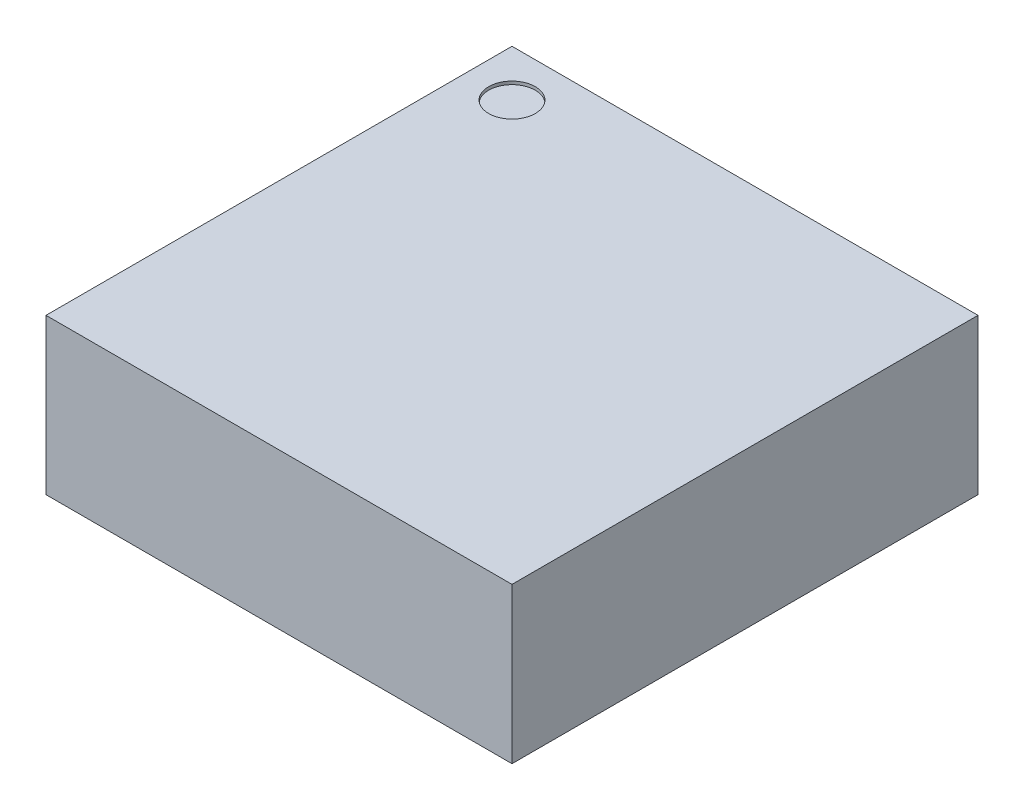
from build123d import *

# Parameters (mm, degrees)
SKETCH1_W           = 3
SKETCH1_H           = 3
BOSS_EXTRUDE1_DEPTH = 1
BOSS_EXTRUDE2_DEPTH = 0.05
SKETCH3_R           = 0.15
CUT_EXTRUDE1_DEPTH  = 0.02


with BuildPart() as part:
    # Sketch1 → Boss-Extrude1 (new body)
    with BuildSketch(Plane(origin=(0, 0, 0), x_dir=(1, 0, 0), z_dir=(0, 1, 0))):
        Rectangle(SKETCH1_W, SKETCH1_H)
    extrude(amount=BOSS_EXTRUDE1_DEPTH)

    # Sketch2 → Boss-Extrude2 (add)
    with BuildSketch(Plane.XZ):
        with BuildLine():
            Line((-0.6, 1.39), (-0.4, 1.39))
            ThreePointArc((-0.4, 1.39), (-0.364644661, 1.375355339), (-0.35, 1.34))
            Line((-0.35, 1.34), (-0.35, 0.98))
            ThreePointArc((-0.35, 0.98), (-0.5, 0.83), (-0.65, 0.98))
            Line((-0.65, 0.98), (-0.65, 1.34))
            ThreePointArc((-0.65, 1.34), (-0.635355339, 1.375355339), (-0.6, 1.39))
        make_face()
        with BuildLine():
            Line((-0.1, 1.39), (0.1, 1.39))
            ThreePointArc((0.1, 1.39), (0.135355339, 1.375355339), (0.15, 1.34))
            Line((0.15, 1.34), (0.15, 0.98))
            ThreePointArc((0.15, 0.98), (0, 0.83), (-0.15, 0.98))
            Line((-0.15, 0.98), (-0.15, 1.34))
            ThreePointArc((-0.15, 1.34), (-0.135355339, 1.375355339), (-0.1, 1.39))
        make_face()
        with BuildLine():
            Line((0.4, 1.39), (0.6, 1.39))
            ThreePointArc((0.6, 1.39), (0.635355339, 1.375355339), (0.65, 1.34))
            Line((0.65, 1.34), (0.65, 0.98))
            ThreePointArc((0.65, 0.98), (0.5, 0.83), (0.35, 0.98))
            Line((0.35, 0.98), (0.35, 1.34))
            ThreePointArc((0.35, 1.34), (0.364644661, 1.375355339), (0.4, 1.39))
        make_face()
        with BuildLine():
            Line((0.35, -0.98), (0.35, -1.34))
            ThreePointArc((0.35, -1.34), (0.364644661, -1.375355339), (0.4, -1.39))
            Line((0.4, -1.39), (0.6, -1.39))
            ThreePointArc((0.6, -1.39), (0.635355339, -1.375355339), (0.65, -1.34))
            Line((0.65, -1.34), (0.65, -0.98))
            ThreePointArc((0.65, -0.98), (0.5, -0.83), (0.35, -0.98))
        make_face()
        with BuildLine():
            Line((-0.15, -0.98), (-0.15, -1.34))
            ThreePointArc((-0.15, -1.34), (-0.135355339, -1.375355339), (-0.1, -1.39))
            Line((-0.1, -1.39), (0.1, -1.39))
            ThreePointArc((0.1, -1.39), (0.135355339, -1.375355339), (0.15, -1.34))
            Line((0.15, -1.34), (0.15, -0.98))
            ThreePointArc((0.15, -0.98), (0, -0.83), (-0.15, -0.98))
        make_face()
        with BuildLine():
            Line((-0.65, -0.98), (-0.65, -1.34))
            ThreePointArc((-0.65, -1.34), (-0.635355339, -1.375355339), (-0.6, -1.39))
            Line((-0.6, -1.39), (-0.4, -1.39))
            ThreePointArc((-0.4, -1.39), (-0.364644661, -1.375355339), (-0.35, -1.34))
            Line((-0.35, -1.34), (-0.35, -0.98))
            ThreePointArc((-0.35, -0.98), (-0.5, -0.83), (-0.65, -0.98))
        make_face()
        with BuildLine():
            Line((-1.34, 1.15), (-0.98, 1.15))
            ThreePointArc((-0.98, 1.15), (-0.83, 1), (-0.98, 0.85))
            Line((-0.98, 0.85), (-1.34, 0.85))
            ThreePointArc((-1.34, 0.85), (-1.375355339, 0.864644661), (-1.39, 0.9))
            Line((-1.39, 0.9), (-1.39, 1.1))
            ThreePointArc((-1.39, 1.1), (-1.375355339, 1.135355339), (-1.34, 1.15))
        make_face()
        with BuildLine():
            Line((-1.34, 0.65), (-0.98, 0.65))
            ThreePointArc((-0.98, 0.65), (-0.83, 0.5), (-0.98, 0.35))
            Line((-0.98, 0.35), (-1.34, 0.35))
            ThreePointArc((-1.34, 0.35), (-1.375355339, 0.364644661), (-1.39, 0.4))
            Line((-1.39, 0.4), (-1.39, 0.6))
            ThreePointArc((-1.39, 0.6), (-1.375355339, 0.635355339), (-1.34, 0.65))
        make_face()
        with BuildLine():
            Line((-1.34, 0.15), (-0.98, 0.15))
            ThreePointArc((-0.98, 0.15), (-0.83, 0), (-0.98, -0.15))
            Line((-0.98, -0.15), (-1.34, -0.15))
            ThreePointArc((-1.34, -0.15), (-1.375355339, -0.135355339), (-1.39, -0.1))
            Line((-1.39, -0.1), (-1.39, 0.1))
            ThreePointArc((-1.39, 0.1), (-1.375355339, 0.135355339), (-1.34, 0.15))
        make_face()
        with BuildLine():
            Line((-1.34, -0.35), (-0.98, -0.35))
            ThreePointArc((-0.98, -0.35), (-0.83, -0.5), (-0.98, -0.65))
            Line((-0.98, -0.65), (-1.34, -0.65))
            ThreePointArc((-1.34, -0.65), (-1.375355339, -0.635355339), (-1.39, -0.6))
            Line((-1.39, -0.6), (-1.39, -0.4))
            ThreePointArc((-1.39, -0.4), (-1.375355339, -0.364644661), (-1.34, -0.35))
        make_face()
        with BuildLine():
            Line((-1.34, -0.85), (-0.98, -0.85))
            Line((-0.98, -0.85), (-0.88, -0.85))
            ThreePointArc((-0.88, -0.85), (-0.844644661, -0.864644661), (-0.83, -0.9))
            Line((-0.83, -0.9), (-0.83, -1))
            Line((-0.83, -1), (-0.98, -1.15))
            Line((-0.98, -1.15), (-1.34, -1.15))
            ThreePointArc((-1.34, -1.15), (-1.375355339, -1.135355339), (-1.39, -1.1))
            Line((-1.39, -1.1), (-1.39, -0.9))
            ThreePointArc((-1.39, -0.9), (-1.375355339, -0.864644661), (-1.34, -0.85))
        make_face()
        with BuildLine():
            Line((0.98, -0.35), (1.34, -0.35))
            ThreePointArc((1.34, -0.35), (1.375355339, -0.364644661), (1.39, -0.4))
            Line((1.39, -0.4), (1.39, -0.6))
            ThreePointArc((1.39, -0.6), (1.375355339, -0.635355339), (1.34, -0.65))
            Line((1.34, -0.65), (0.98, -0.65))
            ThreePointArc((0.98, -0.65), (0.83, -0.5), (0.98, -0.35))
        make_face()
        with BuildLine():
            Line((0.98, -0.85), (1.34, -0.85))
            ThreePointArc((1.34, -0.85), (1.375355339, -0.864644661), (1.39, -0.9))
            Line((1.39, -0.9), (1.39, -1.1))
            ThreePointArc((1.39, -1.1), (1.375355339, -1.135355339), (1.34, -1.15))
            Line((1.34, -1.15), (0.98, -1.15))
            ThreePointArc((0.98, -1.15), (0.83, -1), (0.98, -0.85))
        make_face()
        with BuildLine():
            Line((0.98, 0.15), (1.34, 0.15))
            ThreePointArc((1.34, 0.15), (1.375355339, 0.135355339), (1.39, 0.1))
            Line((1.39, 0.1), (1.39, -0.1))
            ThreePointArc((1.39, -0.1), (1.375355339, -0.135355339), (1.34, -0.15))
            Line((1.34, -0.15), (0.98, -0.15))
            ThreePointArc((0.98, -0.15), (0.83, 0), (0.98, 0.15))
        make_face()
        with BuildLine():
            Line((0.98, 0.65), (1.34, 0.65))
            ThreePointArc((1.34, 0.65), (1.375355339, 0.635355339), (1.39, 0.6))
            Line((1.39, 0.6), (1.39, 0.4))
            ThreePointArc((1.39, 0.4), (1.375355339, 0.364644661), (1.34, 0.35))
            Line((1.34, 0.35), (0.98, 0.35))
            ThreePointArc((0.98, 0.35), (0.83, 0.5), (0.98, 0.65))
        make_face()
        with BuildLine():
            Line((0.98, 1.15), (1.34, 1.15))
            ThreePointArc((1.34, 1.15), (1.375355339, 1.135355339), (1.39, 1.1))
            Line((1.39, 1.1), (1.39, 0.9))
            ThreePointArc((1.39, 0.9), (1.375355339, 0.864644661), (1.34, 0.85))
            Line((1.34, 0.85), (0.98, 0.85))
            ThreePointArc((0.98, 0.85), (0.83, 1), (0.98, 1.15))
        make_face()
    extrude(amount=BOSS_EXTRUDE2_DEPTH)

    # Sketch3 → Cut-Extrude1 (cut)
    with BuildSketch(Plane(origin=(0, 1, 0), x_dir=(1, 0, 0), z_dir=(0, 1, 0))):
        with Locations((-1.2, 1.2)):
            Circle(SKETCH3_R)
    extrude(amount=-CUT_EXTRUDE1_DEPTH, mode=Mode.SUBTRACT)


solid = part.part
